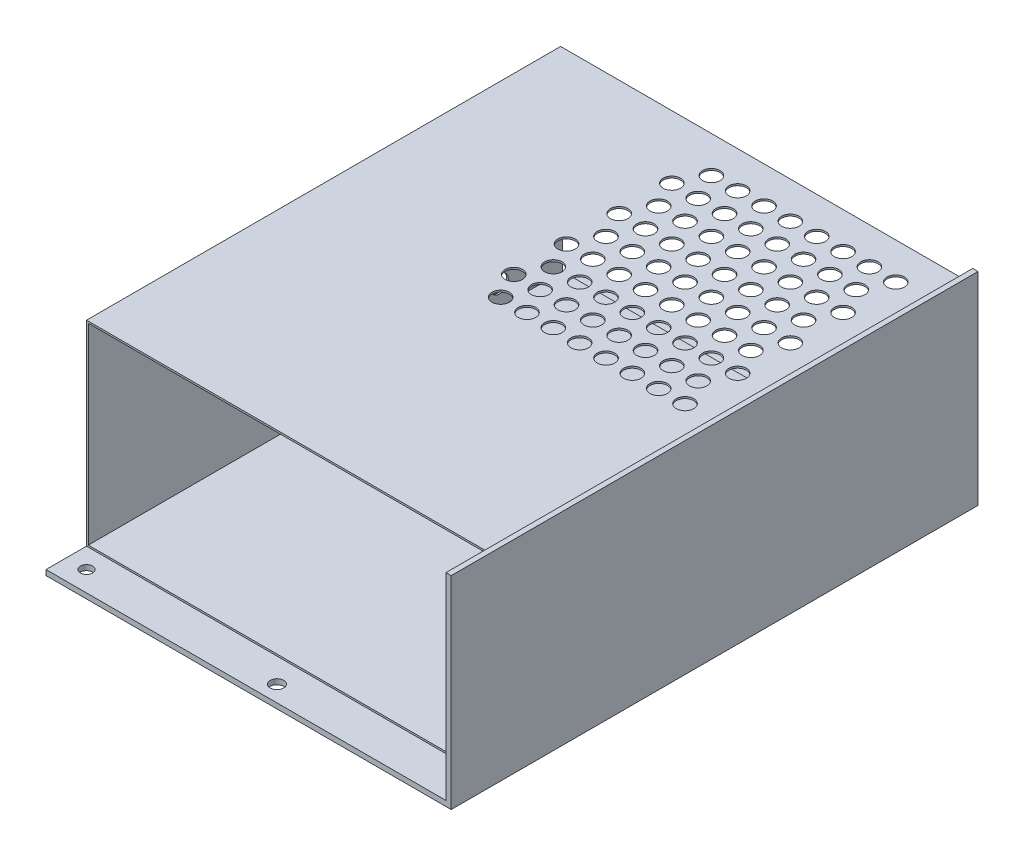
from build123d import *

# Parameters (mm, degrees)
SKETCH1_W           = 100
SKETCH1_H           = 130
BOSS_EXTRUDE1_DEPTH = 1.3
SKETCH2_W           = 1.3
SKETCH2_H           = 130
BOSS_EXTRUDE2_DEPTH = 48.7
CUT_EXTRUDE1_REACH  = 3.3
SKETCH3_R           = 1.5
SKETCH3_R_2         = 1.65
SKETCH4_W           = 98.7
SKETCH4_H           = 117
BOSS_EXTRUDE3_DEPTH = 48.3
SHELL1_T            = -0.44
SKETCH5_R           = 2.15
CUT_EXTRUDE2_DEPTH  = 0.44
SKETCH6_R           = 2.15
CUT_EXTRUDE3_DEPTH  = 0.44


with BuildPart() as part:
    # Sketch1 → Boss-Extrude1 (new body)
    with BuildSketch(Plane(origin=(0, 0, 0), x_dir=(1, 0, 0), z_dir=(0, 1, 0))):
        Rectangle(SKETCH1_W, SKETCH1_H)
    extrude(amount=BOSS_EXTRUDE1_DEPTH)

    # Sketch2 → Boss-Extrude2 (add)
    with BuildSketch(Plane(origin=(0, 1.3, 0), x_dir=(1, 0, 0), z_dir=(0, 1, 0))):
        with Locations((49.35, 0)):
            Rectangle(SKETCH2_W, SKETCH2_H)
    extrude(amount=BOSS_EXTRUDE2_DEPTH)

    # Sketch3 → Cut-Extrude1 (cut, up to next)
    with BuildSketch(Plane(origin=(0, 1.3, 0), x_dir=(1, 0, 0), z_dir=(0, 1, 0)), mode=Mode.PRIVATE) as cut_extrude1_sk1:
        with Locations((-45, -60)):
            Circle(SKETCH3_R)
    cut_extrude1_tool1 = extrude(cut_extrude1_sk1.sketch, amount=-CUT_EXTRUDE1_REACH, mode=Mode.PRIVATE) & part.part
    add(cut_extrude1_tool1.solids().sort_by_distance((-45, 1.3, 60))[0], mode=Mode.SUBTRACT)
    # Sketch3 → Cut-Extrude1 (cut, up to next)
    with BuildSketch(Plane(origin=(0, 1.3, 0), x_dir=(1, 0, 0), z_dir=(0, 1, 0)), mode=Mode.PRIVATE) as cut_extrude1_sk2:
        with Locations((-45, 7)):
            Circle(SKETCH3_R)
    cut_extrude1_tool2 = extrude(cut_extrude1_sk2.sketch, amount=-CUT_EXTRUDE1_REACH, mode=Mode.PRIVATE) & part.part
    add(cut_extrude1_tool2.solids().sort_by_distance((-45, 1.3, -7))[0], mode=Mode.SUBTRACT)
    # Sketch3 → Cut-Extrude1 (cut, up to next)
    with BuildSketch(Plane(origin=(0, 1.3, 0), x_dir=(1, 0, 0), z_dir=(0, 1, 0)), mode=Mode.PRIVATE) as cut_extrude1_sk3:
        with Locations((3, -61)):
            Circle(SKETCH3_R_2)
    cut_extrude1_tool3 = extrude(cut_extrude1_sk3.sketch, amount=-CUT_EXTRUDE1_REACH, mode=Mode.PRIVATE) & part.part
    add(cut_extrude1_tool3.solids().sort_by_distance((3, 1.3, 61))[0], mode=Mode.SUBTRACT)


with BuildPart() as body_2:
    # Sketch4 → Boss-Extrude3 (new body)
    with BuildSketch(Plane(origin=(0, 1.3, 0), x_dir=(1, 0, 0), z_dir=(0, 1, 0))):
        with Locations((-0.65, 3.5)):
            Rectangle(SKETCH4_W, SKETCH4_H)
    extrude(amount=BOSS_EXTRUDE3_DEPTH)

    # Shell1
    shell1_openings = [body_2.faces().sort_by_distance(p)[0] for p in [
        (-0.65, 25.45, 55),
        (-0.65, 25.45, -62),
    ]]
    offset(amount=SHELL1_T, openings=shell1_openings, kind=Kind.INTERSECTION)

    # Sketch5 → Cut-Extrude2 (cut)
    with BuildSketch(Plane(origin=(0, 49.6, 0), x_dir=(1, 0, 0), z_dir=(0, 1, 0))):
        with Locations((41.7, 53)):
            Circle(SKETCH5_R)
        with Locations((38.45, 46.5)):
            Circle(SKETCH5_R)
        with Locations((35.2, 53)):
            Circle(SKETCH5_R)
        with Locations((31.95, 46.5)):
            Circle(SKETCH5_R)
        with Locations((28.7, 53)):
            Circle(SKETCH5_R)
        with Locations((25.45, 46.5)):
            Circle(SKETCH5_R)
        with Locations((22.2, 53)):
            Circle(SKETCH5_R)
        with Locations((18.95, 46.5)):
            Circle(SKETCH5_R)
        with Locations((15.7, 53)):
            Circle(SKETCH5_R)
        with Locations((12.45, 46.5)):
            Circle(SKETCH5_R)
        with Locations((9.2, 53)):
            Circle(SKETCH5_R)
        with Locations((5.95, 46.5)):
            Circle(SKETCH5_R)
        with Locations((2.7, 53)):
            Circle(SKETCH5_R)
        with Locations((-0.55, 46.5)):
            Circle(SKETCH5_R)
        with Locations((-3.8, 53)):
            Circle(SKETCH5_R)
        with Locations((-7.05, 46.5)):
            Circle(SKETCH5_R)
        with Locations((41.7, 40)):
            Circle(SKETCH5_R)
        with Locations((38.45, 33.5)):
            Circle(SKETCH5_R)
        with Locations((35.2, 40)):
            Circle(SKETCH5_R)
        with Locations((31.95, 33.5)):
            Circle(SKETCH5_R)
        with Locations((28.7, 40)):
            Circle(SKETCH5_R)
        with Locations((25.45, 33.5)):
            Circle(SKETCH5_R)
        with Locations((22.2, 40)):
            Circle(SKETCH5_R)
        with Locations((18.95, 33.5)):
            Circle(SKETCH5_R)
        with Locations((15.7, 40)):
            Circle(SKETCH5_R)
        with Locations((12.45, 33.5)):
            Circle(SKETCH5_R)
        with Locations((9.2, 40)):
            Circle(SKETCH5_R)
        with Locations((5.95, 33.5)):
            Circle(SKETCH5_R)
        with Locations((2.7, 40)):
            Circle(SKETCH5_R)
        with Locations((-0.55, 33.5)):
            Circle(SKETCH5_R)
        with Locations((-3.8, 40)):
            Circle(SKETCH5_R)
        with Locations((-7.05, 33.5)):
            Circle(SKETCH5_R)
        with Locations((41.7, 27)):
            Circle(SKETCH5_R)
        with Locations((38.45, 20.5)):
            Circle(SKETCH5_R)
        with Locations((35.2, 27)):
            Circle(SKETCH5_R)
        with Locations((31.95, 20.5)):
            Circle(SKETCH5_R)
        with Locations((28.7, 27)):
            Circle(SKETCH5_R)
        with Locations((25.45, 20.5)):
            Circle(SKETCH5_R)
        with Locations((22.2, 27)):
            Circle(SKETCH5_R)
        with Locations((18.95, 20.5)):
            Circle(SKETCH5_R)
        with Locations((15.7, 27)):
            Circle(SKETCH5_R)
        with Locations((12.45, 20.5)):
            Circle(SKETCH5_R)
        with Locations((9.2, 27)):
            Circle(SKETCH5_R)
        with Locations((5.95, 20.5)):
            Circle(SKETCH5_R)
        with Locations((2.7, 27)):
            Circle(SKETCH5_R)
        with Locations((-0.55, 20.5)):
            Circle(SKETCH5_R)
        with Locations((-3.8, 27)):
            Circle(SKETCH5_R)
        with Locations((-7.05, 20.5)):
            Circle(SKETCH5_R)
        with Locations((41.7, 14)):
            Circle(SKETCH5_R)
        with Locations((38.45, 7.5)):
            Circle(SKETCH5_R)
        with Locations((35.2, 14)):
            Circle(SKETCH5_R)
        with Locations((31.95, 7.5)):
            Circle(SKETCH5_R)
        with Locations((28.7, 14)):
            Circle(SKETCH5_R)
        with Locations((25.45, 7.5)):
            Circle(SKETCH5_R)
        with Locations((22.2, 14)):
            Circle(SKETCH5_R)
        with Locations((18.95, 7.5)):
            Circle(SKETCH5_R)
        with Locations((15.7, 14)):
            Circle(SKETCH5_R)
        with Locations((12.45, 7.5)):
            Circle(SKETCH5_R)
        with Locations((9.2, 14)):
            Circle(SKETCH5_R)
        with Locations((5.95, 7.5)):
            Circle(SKETCH5_R)
        with Locations((2.7, 14)):
            Circle(SKETCH5_R)
        with Locations((-0.55, 7.5)):
            Circle(SKETCH5_R)
        with Locations((-3.8, 14)):
            Circle(SKETCH5_R)
        with Locations((-7.05, 7.5)):
            Circle(SKETCH5_R)
        with Locations((41.7, 1)):
            Circle(SKETCH5_R)
        with Locations((35.2, 1)):
            Circle(SKETCH5_R)
        with Locations((28.7, 1)):
            Circle(SKETCH5_R)
        with Locations((22.2, 1)):
            Circle(SKETCH5_R)
        with Locations((15.7, 1)):
            Circle(SKETCH5_R)
        with Locations((9.2, 1)):
            Circle(SKETCH5_R)
        with Locations((2.7, 1)):
            Circle(SKETCH5_R)
        with Locations((-3.8, 1)):
            Circle(SKETCH5_R)
    extrude(amount=-CUT_EXTRUDE2_DEPTH, mode=Mode.SUBTRACT)

    # Sketch6 → Cut-Extrude3 (cut)
    with BuildSketch(Plane.ZY.offset(50)):
        with Locations((-46.5, 6.8)):
            Circle(SKETCH6_R)
        with Locations((-40, 10.05)):
            Circle(SKETCH6_R)
        with Locations((-33.5, 6.8)):
            Circle(SKETCH6_R)
        with Locations((-27, 10.05)):
            Circle(SKETCH6_R)
        with Locations((-20.5, 6.8)):
            Circle(SKETCH6_R)
        with Locations((-14, 10.05)):
            Circle(SKETCH6_R)
        with Locations((-7.5, 6.8)):
            Circle(SKETCH6_R)
        with Locations((-1, 10.05)):
            Circle(SKETCH6_R)
        with Locations((-33.5, 13.3)):
            Circle(SKETCH6_R)
        with Locations((-27, 16.55)):
            Circle(SKETCH6_R)
        with Locations((-20.5, 13.3)):
            Circle(SKETCH6_R)
        with Locations((-14, 16.55)):
            Circle(SKETCH6_R)
        with Locations((-7.5, 13.3)):
            Circle(SKETCH6_R)
        with Locations((-1, 16.55)):
            Circle(SKETCH6_R)
        with Locations((-33.5, 19.8)):
            Circle(SKETCH6_R)
        with Locations((-27, 23.05)):
            Circle(SKETCH6_R)
        with Locations((-20.5, 19.8)):
            Circle(SKETCH6_R)
        with Locations((-14, 23.05)):
            Circle(SKETCH6_R)
        with Locations((-7.5, 19.8)):
            Circle(SKETCH6_R)
        with Locations((-1, 23.05)):
            Circle(SKETCH6_R)
        with Locations((-33.5, 26.3)):
            Circle(SKETCH6_R)
        with Locations((-27, 29.55)):
            Circle(SKETCH6_R)
        with Locations((-20.5, 26.3)):
            Circle(SKETCH6_R)
        with Locations((-14, 29.55)):
            Circle(SKETCH6_R)
        with Locations((-7.5, 26.3)):
            Circle(SKETCH6_R)
        with Locations((-1, 29.55)):
            Circle(SKETCH6_R)
        with Locations((-33.5, 32.8)):
            Circle(SKETCH6_R)
        with Locations((-27, 36.05)):
            Circle(SKETCH6_R)
        with Locations((-20.5, 32.8)):
            Circle(SKETCH6_R)
        with Locations((-14, 36.05)):
            Circle(SKETCH6_R)
        with Locations((-7.5, 32.8)):
            Circle(SKETCH6_R)
        with Locations((-1, 36.05)):
            Circle(SKETCH6_R)
        with Locations((-46.5, 13.3)):
            Circle(SKETCH6_R)
        with Locations((-40, 16.55)):
            Circle(SKETCH6_R)
        with Locations((-46.5, 19.8)):
            Circle(SKETCH6_R)
        with Locations((-40, 23.05)):
            Circle(SKETCH6_R)
        with Locations((-46.5, 26.3)):
            Circle(SKETCH6_R)
        with Locations((-40, 29.55)):
            Circle(SKETCH6_R)
        with Locations((-46.5, 32.8)):
            Circle(SKETCH6_R)
        with Locations((-40, 36.05)):
            Circle(SKETCH6_R)
    extrude(amount=-CUT_EXTRUDE3_DEPTH, mode=Mode.SUBTRACT)


solid = Compound([part.part, body_2.part])
